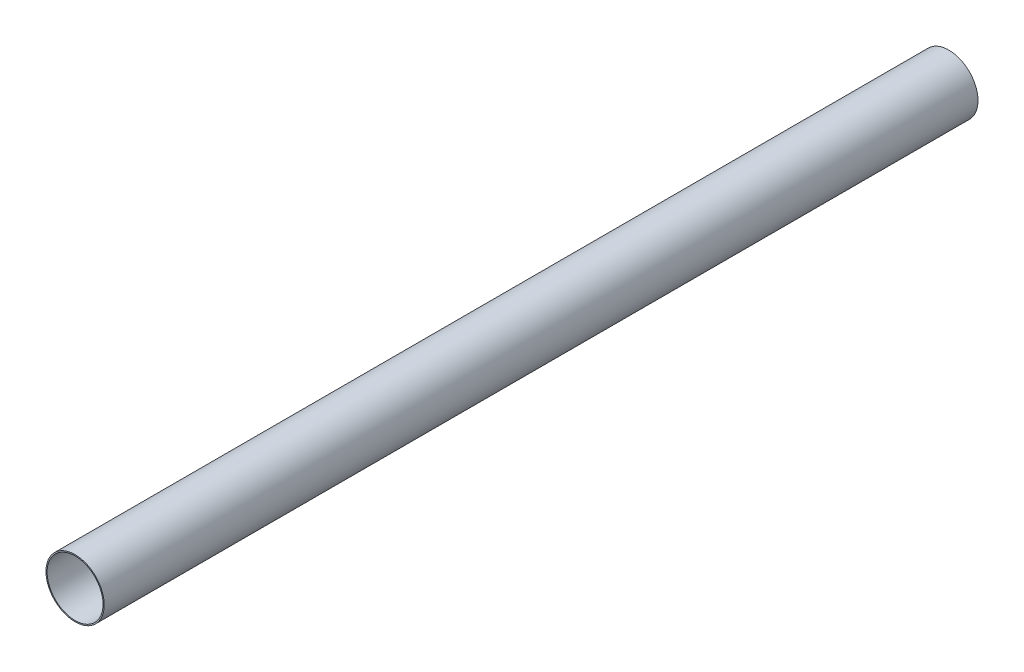
from build123d import *

# Parameters (mm, degrees)
SKETCH1_R           = 50.8
SKETCH1_R_2         = 48.8061
BOSS_EXTRUDE1_DEPTH = 1524


with BuildPart() as part:
    # Sketch1 → Boss-Extrude1 (new body)
    with BuildSketch(Plane.XY):
        Circle(SKETCH1_R)
        Circle(SKETCH1_R_2, mode=Mode.SUBTRACT)
    extrude(amount=BOSS_EXTRUDE1_DEPTH)


solid = part.part
